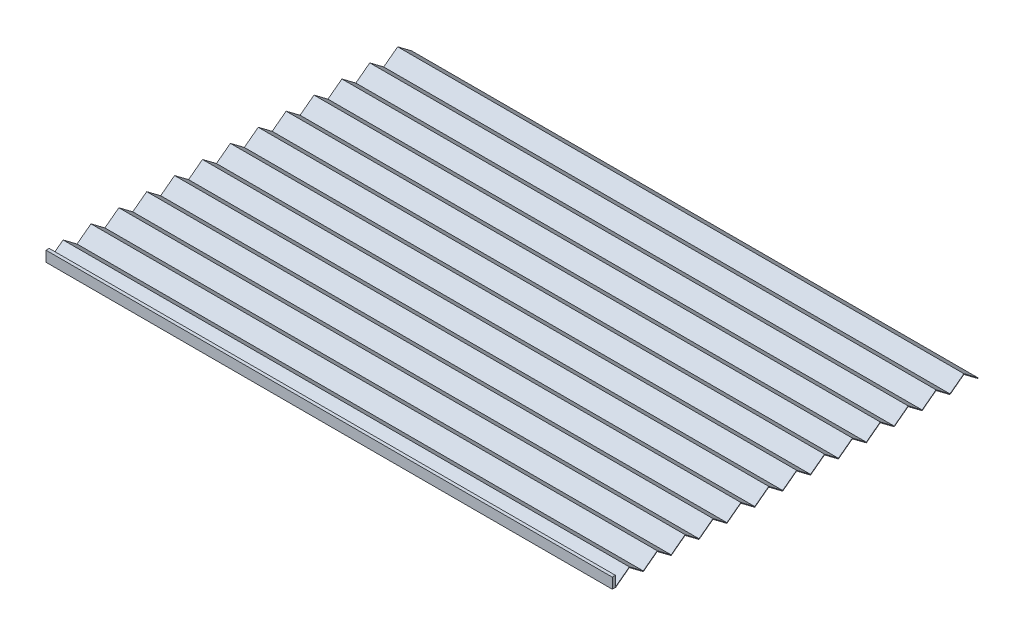
from build123d import *

# Parameters (mm, degrees)
SKETCH2_W           = 540
SKETCH2_H           = 10
BOSS_EXTRUDE1_DEPTH = 3
EXTRUDE_THIN1_DEPTH = 540


with BuildPart() as part:
    # Sketch2 → Boss-Extrude1 (new body)
    with BuildSketch(Plane.XY):
        with Locations((0, 5)):
            Rectangle(SKETCH2_W, SKETCH2_H)
    extrude(amount=BOSS_EXTRUDE1_DEPTH)

    # Sketch3 → Extrude-Thin1 (add, through all)
    with BuildSketch(Plane(origin=(270, 0, 0), x_dir=(0, 0, -1), z_dir=(1, 0, 0))):
        Polygon((0.150284541, -0.199786278), (13.293867572, 9.687165702), (26.587735145, -0.312834298), (39.881602717, 9.687165702), (53.175470289, -0.312834298), (66.469337861, 9.687165702), (79.763205434, -0.312834298), (93.057073006, 9.687165702), (106.350940578, -0.312834298), (119.64480815, 9.687165702), (132.938675723, -0.312834298), (146.232543295, 9.687165702), (159.526410867, -0.312834298), (172.820278439, 9.687165702), (186.114146012, -0.312834298), (199.408013584, 9.687165702), (212.701881156, -0.312834298), (225.995748728, 9.687165702), (239.289616301, -0.312834298), (252.583483873, 9.687165702), (265.877351445, -0.312834298), (279.171219017, 9.687165702), (292.46508659, -0.312834298), (305.758954162, 9.687165702), (319.052821734, -0.312834298), (332.346689306, 9.687165702), (345.490272338, -0.199786278), (345.790841419, 0.199786278), (332.346689306, 10.312834298), (319.052821734, 0.312834298), (305.758954162, 10.312834298), (292.46508659, 0.312834298), (279.171219017, 10.312834298), (265.877351445, 0.312834298), (252.583483873, 10.312834298), (239.289616301, 0.312834298), (225.995748728, 10.312834298), (212.701881156, 0.312834298), (199.408013584, 10.312834298), (186.114146012, 0.312834298), (172.820278439, 10.312834298), (159.526410867, 0.312834298), (146.232543295, 10.312834298), (132.938675723, 0.312834298), (119.64480815, 10.312834298), (106.350940578, 0.312834298), (93.057073006, 10.312834298), (79.763205434, 0.312834298), (66.469337861, 10.312834298), (53.175470289, 0.312834298), (39.881602717, 10.312834298), (26.587735145, 0.312834298), (13.293867572, 10.312834298), (-0.150284541, 0.199786278), align=None)
    extrude(amount=-EXTRUDE_THIN1_DEPTH)


solid = part.part
